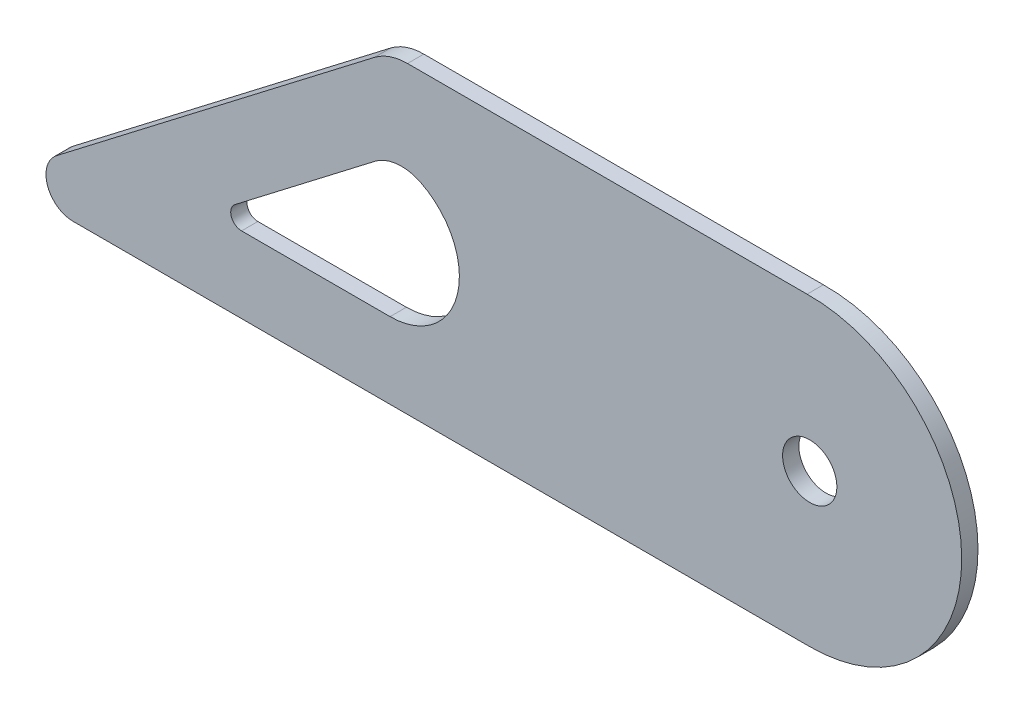
from build123d import *

# Parameters (mm, degrees)
SKETCH2_R           = 25
BOSS_EXTRUDE1_DEPTH = 7.5


with BuildPart() as part:
    # Sketch2 → Boss-Extrude1 (new body, symmetric)
    with BuildSketch(Plane.XY):
        with BuildLine():
            Line((-398.468541926, -10.340558916), (-691.280931438, -235.14913744))
            ThreePointArc((-691.280931438, -235.14913744), (-699.728704435, -263.018042843), (-676.056537091, -279.978857982))
            Line((-676.056537091, -279.978857982), (2.432964843, -279.978857982))
            ThreePointArc((2.432964843, -279.978857982), (142.427679239, -138.762329632), (0, 0))
            Line((0, 0), (-368.019753232, 0))
            ThreePointArc((-368.019753232, 0), (-384.098122954, -2.655665311), (-398.468541926, -10.340558916))
        make_face()
        with Locations((2.432964843, -139.978857982)):
            Circle(SKETCH2_R, mode=Mode.SUBTRACT)
        with BuildLine():
            Line((-526.980915272, -192.046969766), (-398.014187587, -93.031942512))
            ThreePointArc((-398.014187587, -93.031942512), (-377.665337115, -84.961022387), (-356.115398822, -88.810129655))
            ThreePointArc((-356.115398822, -88.810129655), (-321.919160325, -160.522945456), (-384.098122954, -209.978857982))
            Line((-384.098122954, -209.978857982), (-520.891157533, -209.978857982))
            ThreePointArc((-520.891157533, -209.978857982), (-530.360024471, -203.194531927), (-526.980915272, -192.046969766))
        make_face(mode=Mode.SUBTRACT)
    extrude(amount=BOSS_EXTRUDE1_DEPTH, both=True)


solid = part.part
